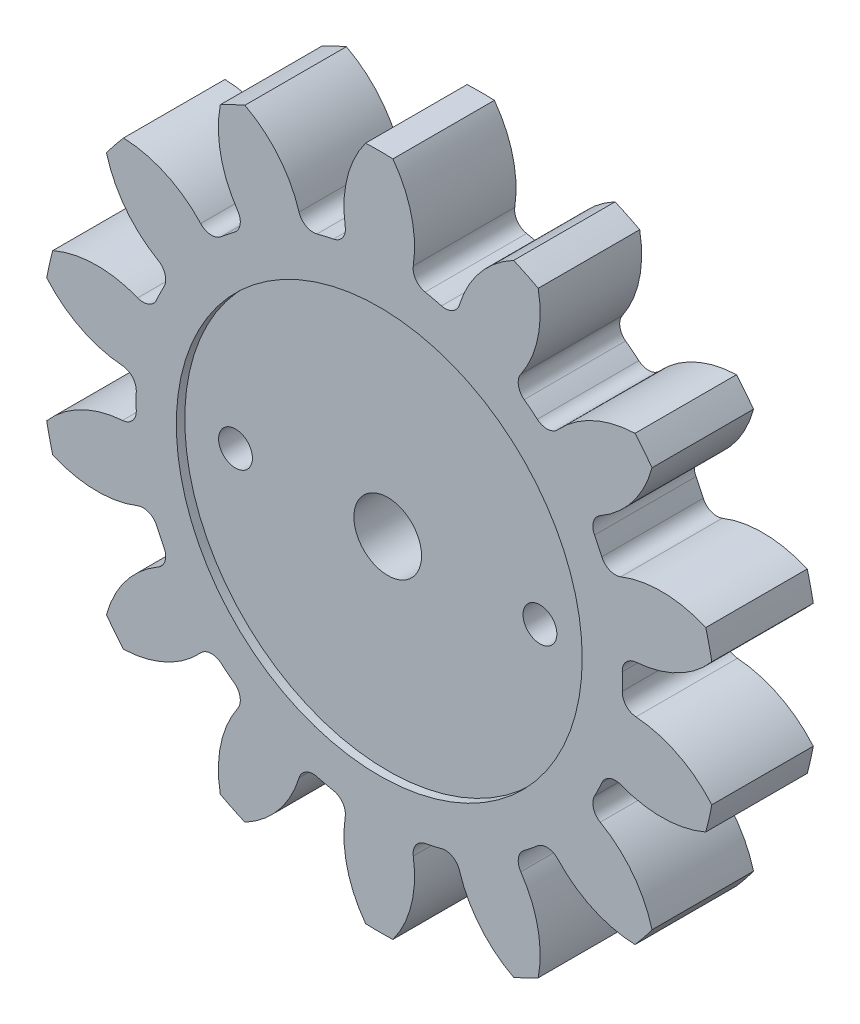
from build123d import *

# Parameters (mm, degrees)
BOSS_EXTRU_1_DEPTH                 = 6
CONG_1_R                           = 0.875
R_P_TITION_CIRCULAIRE4_COUNT       = 14
CONG_1_OF_R_P_TITION_CIRCULAIRE4_R = 0.875
ESQUISSE6_R                        = 12
ENL_V_MAT_EXTRU_1_DEPTH            = 0.5
ESQUISSE7_R                        = 2
ENL_V_MAT_EXTRU_2_DEPTH            = 6.5000001
ESQUISSE8_R                        = 1
ENL_V_MAT_EXTRU_3_DEPTH            = 6.5000001
ENL_V_MAT_EXTRU_4_DEPTH            = 2


with BuildPart() as part:
    # Esquisse3 → Boss.-Extru.1 (new body)
    with BuildSketch(Plane.XY):
        with BuildLine():
            Line((-4.577445339, 13.454236279), (-1.378706913, -0.560352459))
            Line((-1.378706913, -0.560352459), (1.820031512, 13.454236279))
            ThreePointArc((1.820031512, 13.454236279), (1.134989636, 13.593161404), (0.444004358, 13.69862186))
            ThreePointArc((0.444004358, 13.69862186), (0.608952116, 16.680304966), (-0.571450192, 19.423349315))
            ThreePointArc((-0.571450192, 19.423349315), (-1.378706913, 19.439647541), (-2.185963634, 19.423349315))
            ThreePointArc((-2.185963634, 19.423349315), (-3.366365942, 16.680304966), (-3.201418184, 13.69862186))
            ThreePointArc((-3.201418184, 13.69862186), (-3.892403463, 13.593161404), (-4.577445339, 13.454236279))
        make_face()
    boss_extru_1 = extrude(amount=BOSS_EXTRU_1_DEPTH)

    # Cong_1
    cong_1_edges = [part.edges().sort_by_distance(p)[0] for p in [
        (-3.201418184, 13.69862186, 3),
        (0.444004358, 13.69862186, 3),
    ]]
    fillet(cong_1_edges, radius=CONG_1_R)

    # R_p_tition circulaire4: Boss.-Extru.1 ×14 about axis
    r_p_tition_circulaire4_axis = Axis((-1.378706913, -0.560352459, 0), (0, 0, 1))
    for i in range(1, R_P_TITION_CIRCULAIRE4_COUNT):
        add(boss_extru_1.rotate(r_p_tition_circulaire4_axis, i * 360 / R_P_TITION_CIRCULAIRE4_COUNT))

    # Cong_1 of R_p_tition circulaire4
    cong_1_of_r_p_tition_circulaire4_edges = [part.edges().sort_by_distance(p)[0] for p in [
        (-9.207650117, 11.495694709, 3),
        (-5.923237896, 13.077384272, 3),
        (-13.663263833, 6.904919559, 3),
        (-11.390380054, 9.755025669, 3),
        (-15.68577039, 0.83555573, 3),
        (-14.874587561, 4.389579918, 3),
        (-14.874587561, -5.510284835, 3),
        (-15.68577039, -1.956260647, 3),
        (-11.390380054, -10.875730587, 3),
        (-13.663263833, -8.025624476, 3),
        (-5.923237896, -14.19808919, 3),
        (-9.207650117, -12.616399626, 3),
        (0.444004358, -14.819326777, 3),
        (-3.201418184, -14.819326777, 3),
        (6.450236291, -12.616399626, 3),
        (3.16582407, -14.19808919, 3),
        (10.905850006, -8.025624476, 3),
        (8.632966228, -10.875730587, 3),
        (12.928356564, -1.956260647, 3),
        (12.117173735, -5.510284835, 3),
        (12.117173735, 4.389579918, 3),
        (12.928356564, 0.83555573, 3),
        (8.632966228, 9.755025669, 3),
        (10.905850006, 6.904919559, 3),
        (3.16582407, 13.077384272, 3),
        (6.450236291, 11.495694709, 3),
    ]]
    fillet(cong_1_of_r_p_tition_circulaire4_edges, radius=CONG_1_OF_R_P_TITION_CIRCULAIRE4_R)

    # Esquisse6 → Enl_v. mat.-Extru.1 (cut)
    with BuildSketch(Plane.XY.offset(6)):
        with Locations((-1.378706913, -0.560352459)):
            Circle(ESQUISSE6_R)
    extrude(amount=-ENL_V_MAT_EXTRU_1_DEPTH, mode=Mode.SUBTRACT)

    # Esquisse7 → Enl_v. mat.-Extru.2 (cut, through all)
    with BuildSketch(Plane.XY.offset(5.5)):
        with Locations((-1.378706913, -0.560352459)):
            Circle(ESQUISSE7_R)
    extrude(amount=-ENL_V_MAT_EXTRU_2_DEPTH, mode=Mode.SUBTRACT)

    # Esquisse8 → Enl_v. mat.-Extru.3 (cut, through all)
    with BuildSketch(Plane.XY.offset(5.5)):
        with Locations((-10.378706913, -0.560352459)):
            Circle(ESQUISSE8_R)
        with Locations(Location((7.621293087, -0.560352459, 0), (0, 0, 180))):  # turned: the seam where the file's is
            Circle(ESQUISSE8_R)
    extrude(amount=-ENL_V_MAT_EXTRU_3_DEPTH, mode=Mode.SUBTRACT)

    # Esquisse9 → Enl_v. mat.-Extru.4 (cut)
    with BuildSketch(Plane(origin=(0, 0, 0), x_dir=(-1, 0, 0), z_dir=(0, 0, -1))):
        Polygon((-4.850011795, -2.160352459), (-4.850011795, 1.039647541), (-7.621293087, 2.639647541), (-10.392574379, 1.039647541), (-10.392574379, -2.160352459), (-7.621293087, -3.760352459), align=None)
        Polygon((10.378706913, -3.760352459), (13.149988205, -2.160352459), (13.149988205, 1.039647541), (10.378706913, 2.639647541), (7.607425621, 1.039647541), (7.607425621, -2.160352459), align=None)
    extrude(amount=-ENL_V_MAT_EXTRU_4_DEPTH, mode=Mode.SUBTRACT)


solid = part.part
